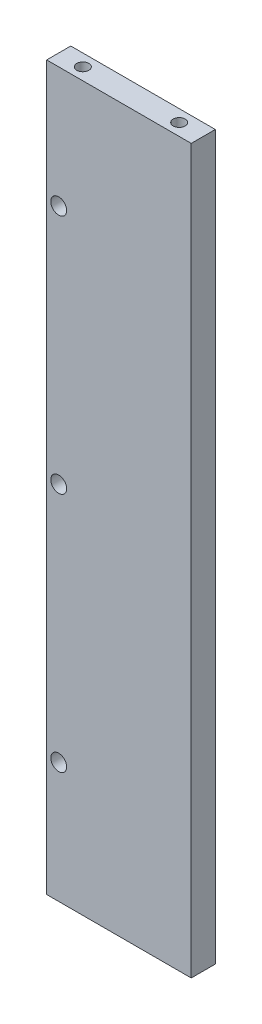
from build123d import *

# Parameters (mm, degrees)
SKETCH1_W                  = 60
SKETCH1_H                  = 300
BOSS_EXTRUDE1_DEPTH        = 10
M6_TAPPED_HOLE1_D          = 5
M6_TAPPED_HOLE1_DEPTH      = 23
M6_TAPPED_HOLE1_TIP        = 1.502151548
M6_TAPPED_HOLE2_D          = 5
M6_TAPPED_HOLE2_DEPTH      = 23
M6_TAPPED_HOLE2_TIP        = 1.502151548
F_6_6_6_6_DIAMETER_SLOT1_D = 6.6


with BuildPart() as part:
    # Sketch1 → Boss-Extrude1 (new body)
    with BuildSketch(Plane.XY):
        with Locations((30, 150)):
            Rectangle(SKETCH1_W, SKETCH1_H)
    extrude(amount=BOSS_EXTRUDE1_DEPTH)

    # M6 Tapped Hole1
    with Locations(Plane(origin=(0, 0, 0), x_dir=(-1, 0, 0), z_dir=(0, -1, 0))):
        with Locations((-50, -5), (-10, -5)):
            Hole(M6_TAPPED_HOLE1_D / 2, depth=M6_TAPPED_HOLE1_DEPTH)
            with Locations((0, 0, -(M6_TAPPED_HOLE1_DEPTH + M6_TAPPED_HOLE1_TIP / 2))):  # 118° drill point
                Cone(0, M6_TAPPED_HOLE1_D / 2, M6_TAPPED_HOLE1_TIP, mode=Mode.SUBTRACT)

    # M6 Tapped Hole2
    with Locations(Plane(origin=(0, 300, 0), x_dir=(1, 0, 0), z_dir=(0, 1, 0))):
        with Locations((10, -5), (50, -5)):
            Hole(M6_TAPPED_HOLE2_D / 2, depth=M6_TAPPED_HOLE2_DEPTH)
            with Locations((0, 0, -(M6_TAPPED_HOLE2_DEPTH + M6_TAPPED_HOLE2_TIP / 2))):  # 118° drill point
                Cone(0, M6_TAPPED_HOLE2_D / 2, M6_TAPPED_HOLE2_TIP, mode=Mode.SUBTRACT)

    # Ø6.6 (6.6) Diameter Slot1 (through all)
    with Locations(Plane(origin=(0, 0, 0), x_dir=(-1, 0, 0), z_dir=(0, 0, -1))):
        with Locations((-5, 50), (-5, 150), (-5, 250)):
            Hole(F_6_6_6_6_DIAMETER_SLOT1_D / 2)


solid = part.part
